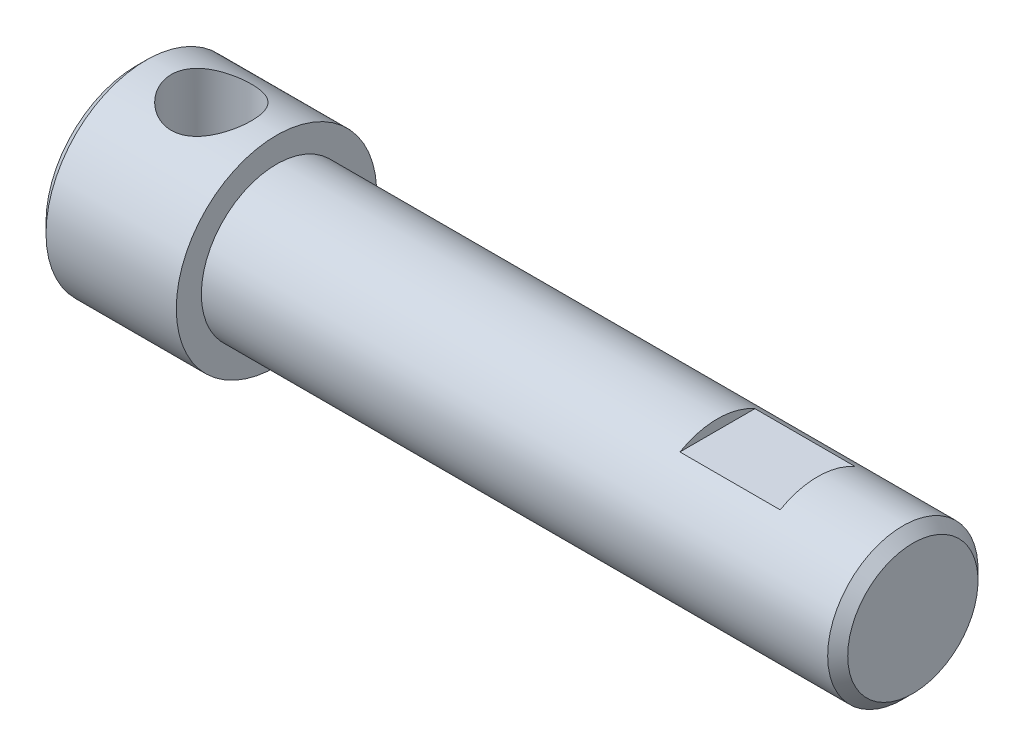
from build123d import *

# Parameters (mm, degrees)
ENL_V_MAT_EXTRU_3_DEPTH      = 4
ENL_V_MAT_EXTRU_3_DEPTH_BACK = 4
ESQUISSE6_W                  = 10
ESQUISSE6_H                  = 1


with BuildPart() as part:
    # Esquisse1 → Révolution5 (revolve)
    with BuildSketch(Plane.XY):
        Polygon((-18.5, 7.5), (44, 7.5), (45, 6.5), (45, 0), (-13.190313779, 0), (-15.499848989, 4.000151011), (-32.499848989, 4.000151011), (-32.499848989, 9.000151011), (-31.5, 10), (-18.5, 10), align=None)
    revolve(axis=Axis((-1000, 0, 0), (1, 0, 0)))

    # Esquisse5 → Enlèvement de matière-Révolution1 (revolve, cut)
    with BuildSketch(Plane.XY):
        Polygon((-29, 10), (-29, 3), (-27.75, 1.75), (-25, 1.75), (-25, 10), align=None)
    revolve(axis=Axis((-25, 1.75, 0), (0, 1, 0)), mode=Mode.SUBTRACT)

    # Esquisse6 → Enlèv. mat.-Extru.3 (cut, two sides: drawn at the far end of the back side and taken through both)
    with BuildSketch(Plane.XY.offset(-ENL_V_MAT_EXTRU_3_DEPTH_BACK)):
        with Locations((30.5, 7)):
            Rectangle(ESQUISSE6_W, ESQUISSE6_H)
    extrude(amount=ENL_V_MAT_EXTRU_3_DEPTH + ENL_V_MAT_EXTRU_3_DEPTH_BACK, mode=Mode.SUBTRACT)


solid = part.part
